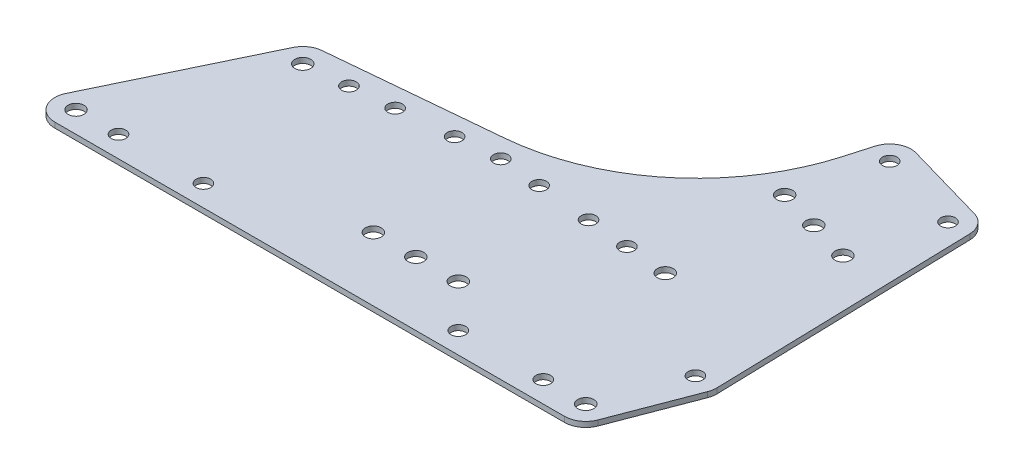
from build123d import *

# Parameters (mm, degrees)
SKETCH1_R           = 2.38125
SKETCH1_R_2         = 2.1828125
BOSS_EXTRUDE1_DEPTH = 1.5875


with BuildPart() as part:
    # Sketch1 → Boss-Extrude1 (new body)
    with BuildSketch(Plane(origin=(0, 0, 0), x_dir=(1, 0, 0), z_dir=(0, 1, 0))):
        with BuildLine():
            Line((0, -6.35), (152.4, -6.35))
            ThreePointArc((152.4, -6.35), (156.001136223, -5.230135553), (158.332104124, -2.265533197))
            Line((158.332104124, -2.265533197), (167.394236912, 21.462883297))
            ThreePointArc((167.394236912, 21.462883297), (167.721572666, 22.659813472), (167.809879929, 23.897550265))
            Line((167.809879929, 23.897550265), (165.742716066, 101.480125789))
            ThreePointArc((165.742716066, 101.480125789), (164.41446111, 105.200361917), (161.143711156, 107.415449457))
            Line((161.143711156, 107.415449457), (136.725881406, 114.410418382))
            ThreePointArc((136.725881406, 114.410418382), (131.897183415, 113.859011684), (128.872681737, 110.054703175))
            Line((128.872681737, 110.054703175), (126.704453603, 102.48591681))
            ThreePointArc((126.704453603, 102.48591681), (106.178087881, 71.080346093), (71.506985471, 56.743114162))
            Line((71.506985471, 56.743114162), (21.41726751, 52.111153689))
            ThreePointArc((21.41726751, 52.111153689), (18.377117757, 51.001852249), (16.278461735, 48.53837846))
            Line((16.278461735, 48.53837846), (-5.723516399, 2.750247267))
            ThreePointArc((-5.723516399, 2.750247267), (-5.375247443, -3.380712192), (0, -6.35))
        make_face()
        Circle(SKETCH1_R, mode=Mode.SUBTRACT)
        with Locations((22.001978134, 45.788131193)):
            Circle(SKETCH1_R, mode=Mode.SUBTRACT)
        with Locations((76.2, 12.7)):
            Circle(SKETCH1_R, mode=Mode.SUBTRACT)
        with Locations((130.398021866, 45.788131193)):
            Circle(SKETCH1_R, mode=Mode.SUBTRACT)
        with Locations((152.4, 0)):
            Circle(SKETCH1_R, mode=Mode.SUBTRACT)
        with Locations((76.2, 50.8)):
            Circle(SKETCH1_R_2, mode=Mode.SUBTRACT)
        with Locations((63.553955008, 49.630578751)):
            Circle(SKETCH1_R_2, mode=Mode.SUBTRACT)
        with Locations((88.846044992, 49.630578751)):
            Circle(SKETCH1_R_2, mode=Mode.SUBTRACT)
        with Locations((117.751976873, 46.957552442)):
            Circle(SKETCH1_R_2, mode=Mode.SUBTRACT)
        with Locations((105.105931881, 48.126973691)):
            Circle(SKETCH1_R_2, mode=Mode.SUBTRACT)
        with Locations((34.648023127, 46.957552442)):
            Circle(SKETCH1_R_2, mode=Mode.SUBTRACT)
        with Locations((47.294068119, 48.126973691)):
            Circle(SKETCH1_R_2, mode=Mode.SUBTRACT)
        with Locations((152.4, 76.893162268)):
            Circle(SKETCH1_R, mode=Mode.SUBTRACT)
        with Locations((127.982170249, 83.888131193)):
            Circle(SKETCH1_R, mode=Mode.SUBTRACT)
        with Locations((140.191085125, 80.390646731)):
            Circle(SKETCH1_R, mode=Mode.SUBTRACT)
        with Locations((134.977139174, 108.305960944)):
            Circle(SKETCH1_R_2, mode=Mode.SUBTRACT)
        with Locations((159.394968925, 101.310992019)):
            Circle(SKETCH1_R_2, mode=Mode.SUBTRACT)
        with Locations((161.462132788, 23.728416494)):
            Circle(SKETCH1_R_2, mode=Mode.SUBTRACT)
        with Locations((12.7, 0)):
            Circle(SKETCH1_R_2, mode=Mode.SUBTRACT)
        with Locations((38.1, 0)):
            Circle(SKETCH1_R_2, mode=Mode.SUBTRACT)
        with Locations((101.6, 12.7)):
            Circle(SKETCH1_R, mode=Mode.SUBTRACT)
        with Locations((88.9, 12.7)):
            Circle(SKETCH1_R, mode=Mode.SUBTRACT)
        with Locations((139.7, 0)):
            Circle(SKETCH1_R_2, mode=Mode.SUBTRACT)
        with Locations((114.3, 0)):
            Circle(SKETCH1_R_2, mode=Mode.SUBTRACT)
    extrude(amount=BOSS_EXTRUDE1_DEPTH)


solid = part.part
